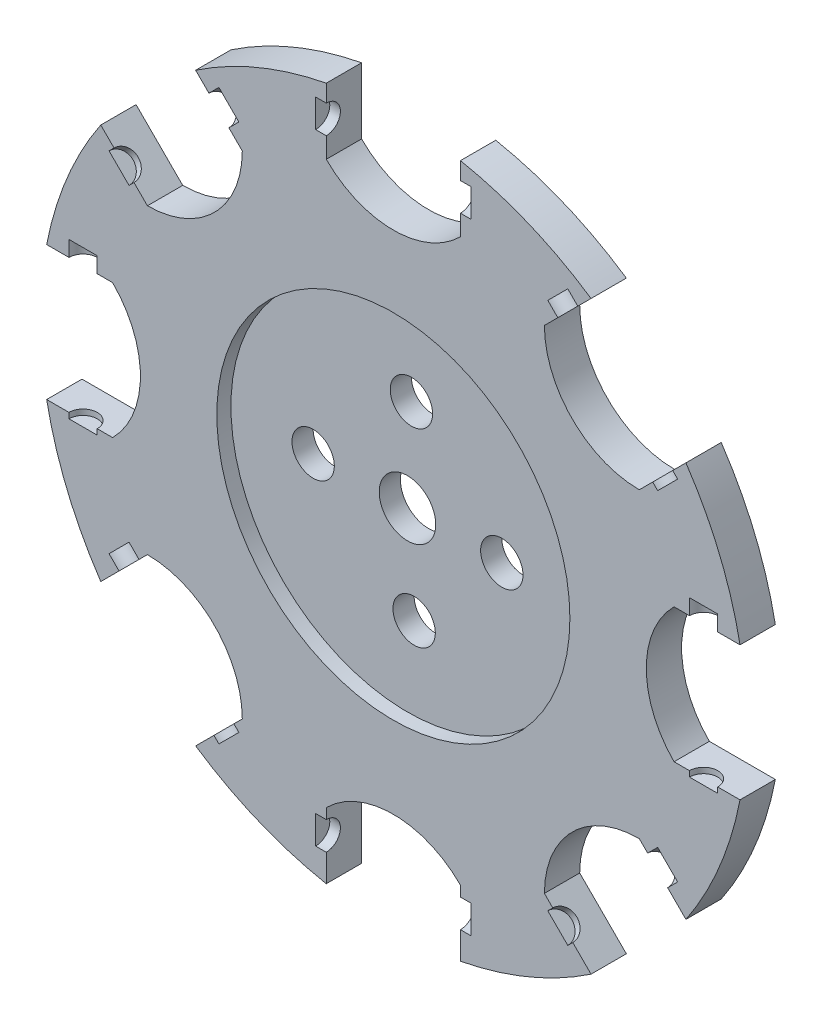
from build123d import *

# Parameters (mm, degrees)
BOSS_EXTRUDE3_DEPTH = 127
SKETCH8_R           = 76.2
SKETCH8_R_2         = 101.6
CUT_EXTRUDE1_DEPTH  = 127
SKETCH9_R           = 635
CUT_EXTRUDE2_DEPTH  = 50.8
SKETCH11_W          = 558.8
SKETCH11_H          = 50.8
CIRPATTERN1_COUNT   = 8


with BuildPart() as part:
    # Sketch6 → Boss-Extrude3 (new body)
    with BuildSketch(Plane.XY):
        with BuildLine():
            Line((40.188095474, 1463.499220044), (40.188095474, 1226.244596849))
            ThreePointArc((40.188095474, 1226.244596849), (281.488095474, 1126.294864248), (522.788095474, 1226.244596849))
            Line((522.788095474, 1226.244596849), (522.788095474, 1463.499220044))
            ThreePointArc((522.788095474, 1463.499220044), (767.496054577, 1389.960431631), (992.530487837, 1268.925550305))
            Line((992.530487837, 1268.925550305), (824.766134908, 1101.161197376))
            ThreePointArc((824.766134908, 1101.161197376), (924.715867509, 859.861197376), (1166.015867509, 759.911464776))
            Line((1166.015867509, 759.911464776), (1333.780220438, 927.675817705))
            ThreePointArc((1333.780220438, 927.675817705), (1454.815101763, 702.641384445), (1528.353890176, 457.933425341))
            Line((1528.353890176, 457.933425341), (1291.099266981, 457.933425341))
            ThreePointArc((1291.099266981, 457.933425341), (1191.149534381, 216.633425341), (1291.099266981, -24.666574659))
            Line((1291.099266981, -24.666574659), (1528.353890176, -24.666574659))
            ThreePointArc((1528.353890176, -24.666574659), (1454.815101763, -269.374533762), (1333.780220438, -494.408967022))
            Line((1333.780220438, -494.408967022), (1166.015867509, -326.644614093))
            ThreePointArc((1166.015867509, -326.644614093), (924.715867509, -426.594346694), (824.766134908, -667.894346694))
            Line((824.766134908, -667.894346694), (992.530487837, -835.658699623))
            ThreePointArc((992.530487837, -835.658699623), (767.496054577, -956.693580948), (522.788095474, -1030.232369362))
            Line((522.788095474, -1030.232369362), (522.788095474, -792.977746166))
            ThreePointArc((522.788095474, -792.977746166), (281.488095474, -693.028013566), (40.188095474, -792.977746166))
            Line((40.188095474, -792.977746166), (40.188095474, -1030.232369362))
            ThreePointArc((40.188095474, -1030.232369362), (-204.51986363, -956.693580948), (-429.55429689, -835.658699623))
            Line((-429.55429689, -835.658699623), (-261.789943961, -667.894346694))
            ThreePointArc((-261.789943961, -667.894346694), (-361.739676561, -426.594346694), (-603.039676561, -326.644614093))
            Line((-603.039676561, -326.644614093), (-770.804029491, -494.408967022))
            ThreePointArc((-770.804029491, -494.408967022), (-891.838910816, -269.374533762), (-965.377699229, -24.666574659))
            Line((-965.377699229, -24.666574659), (-728.123076034, -24.666574659))
            ThreePointArc((-728.123076034, -24.666574659), (-628.173343433, 216.633425341), (-728.123076034, 457.933425341))
            Line((-728.123076034, 457.933425341), (-965.377699229, 457.933425341))
            ThreePointArc((-965.377699229, 457.933425341), (-891.838910816, 702.641384445), (-770.804029491, 927.675817705))
            Line((-770.804029491, 927.675817705), (-603.039676561, 759.911464776))
            ThreePointArc((-603.039676561, 759.911464776), (-361.739676561, 859.861197376), (-261.789943961, 1101.161197376))
            Line((-261.789943961, 1101.161197376), (-429.55429689, 1268.925550305))
            ThreePointArc((-429.55429689, 1268.925550305), (-204.51986363, 1389.960431631), (40.188095474, 1463.499220044))
        make_face()
    extrude(amount=BOSS_EXTRUDE3_DEPTH)

    # Sketch8 → Cut-Extrude1 (cut)
    with BuildSketch(Plane.XY.offset(127)):
        with Locations((295.6976207, 573.667181043)):
            Circle(SKETCH8_R)
        with Locations((305.471077412, -103.754429489)):
            Circle(SKETCH8_R)
        with Locations((-57.795904333, 234.680865806)):
            Circle(SKETCH8_R)
        with Locations((620.77209528, 234.680865806)):
            Circle(SKETCH8_R)
        with Locations((281.488095474, 234.680865806)):
            Circle(SKETCH8_R_2)
    extrude(amount=-CUT_EXTRUDE1_DEPTH, mode=Mode.SUBTRACT)

    # Sketch9 → Cut-Extrude2 (cut)
    with BuildSketch(Plane.XY.offset(127)):
        with Locations((281.488095474, 234.680865806)):
            Circle(SKETCH9_R)
    extrude(amount=-CUT_EXTRUDE2_DEPTH, mode=Mode.SUBTRACT)

    # Sketch11 → Cut-Revolve1 (revolve, cut)
    with BuildSketch(Plane.XY.offset(127)):
        with Locations((281.488095474, 1375.931069595)):
            Rectangle(SKETCH11_W, SKETCH11_H)
    cut_revolve1 = revolve(axis=Axis((560.888095474, 1350.531069595, 127), (-1, 0, 0)), mode=Mode.SUBTRACT)

    # CirPattern1: Cut-Revolve1 ×8 about axis
    cirpattern1_axis = Axis((281.488095474, 234.680865806, 0), (0, 0, 1))
    for i in range(1, CIRPATTERN1_COUNT):
        add(cut_revolve1.rotate(cirpattern1_axis, i * 360 / CIRPATTERN1_COUNT), mode=Mode.SUBTRACT)


solid = part.part
